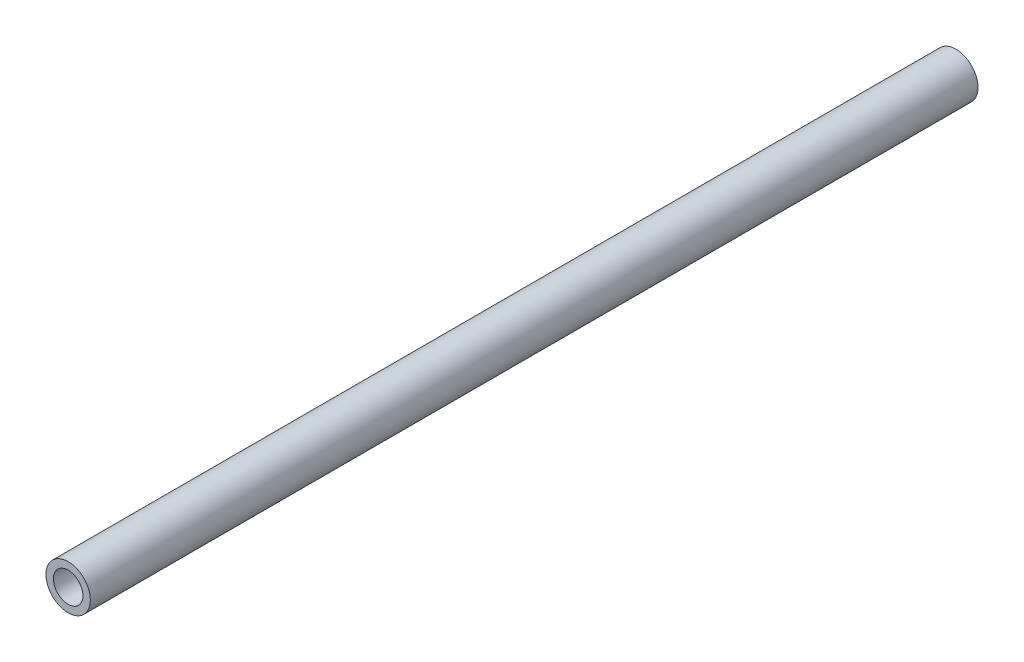
from build123d import *

# Parameters (mm, degrees)
SKETCH2_R           = 3
SKETCH2_R_2         = 2
BOSS_EXTRUDE1_DEPTH = 120


with BuildPart() as part:
    # Sketch2 → Boss-Extrude1 (new body)
    with BuildSketch(Plane.XY):
        Circle(SKETCH2_R)
        Circle(SKETCH2_R_2, mode=Mode.SUBTRACT)
    extrude(amount=BOSS_EXTRUDE1_DEPTH)


solid = part.part
